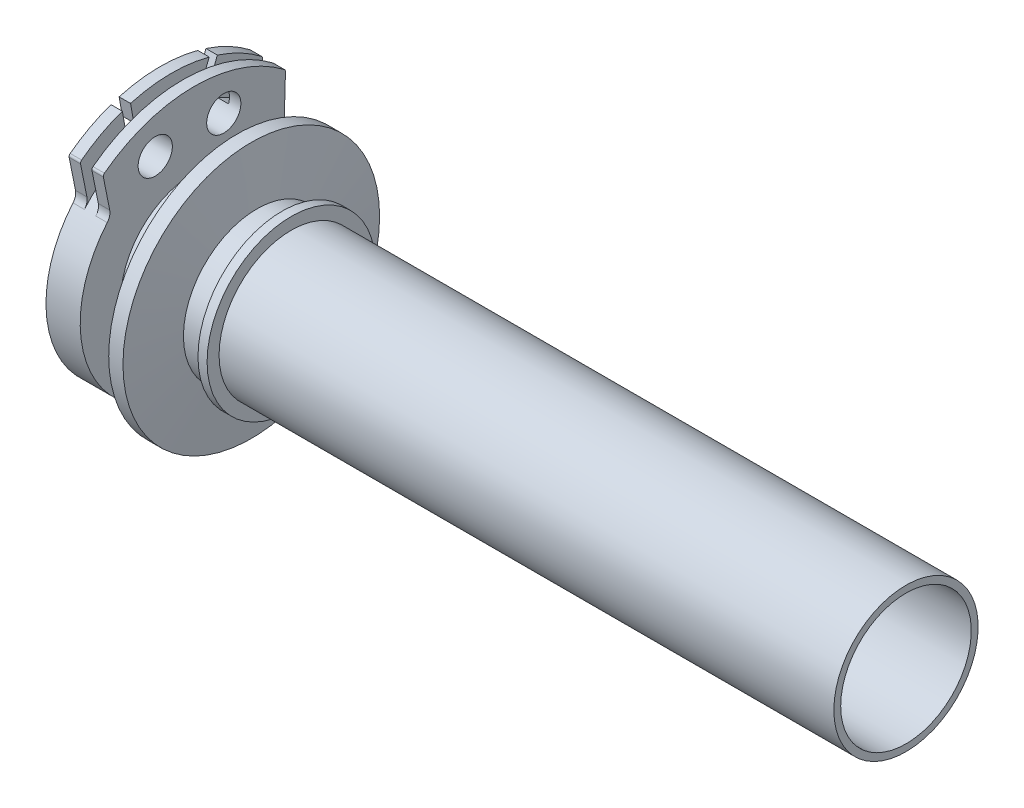
from build123d import *
from build123d.topology import SkipClean

# Parameters (mm, degrees)
SKETCH5_W          = 2
SKETCH5_H          = 25
SKETCH2_R          = 3
CUT_EXTRUDE1_DEPTH = 6
FILLET1_R          = 2
CUT_EXTRUDE2_DEPTH = 6
FILLET2_R          = 0.5
CUT_EXTRUDE3_REACH = 132.8


with BuildPart() as part:
    # Sketch1 → Revolve1 (revolve)
    with BuildSketch(Plane.XY, mode=Mode.PRIVATE) as revolve1_sk:
        Polygon((130.8, 11.45), (0, 11.45), (0, 26), (6, 26), (6, 12.9), (10, 12.9), (10, 15.5), (12, 15.5), (12, 14), (13, 14), (13.5, 22.5), (16, 22.5), (17, 12.9), (21.4, 12.9), (21.4, 14.75), (23, 14.75), (23, 12.65), (130.8, 12.65), align=None)
    revolve(revolve1_sk.sketch.rotate(Axis((0, 0, 0), (1, 0, 0)), 90), axis=Axis((0, 0, 0), (1, 0, 0)))  # turned: the seam where the file's is

    # Sketch5 → Cut-Revolve1 (revolve, cut)
    with BuildSketch(Plane.XY, mode=Mode.PRIVATE) as cut_revolve1_sk:
        with Locations((3, 32.5)):
            Rectangle(SKETCH5_W, SKETCH5_H)
    revolve(cut_revolve1_sk.sketch.rotate(Axis((0, 0, 0), (-1, 0, 0)), 270), axis=Axis((0, 0, 0), (-1, 0, 0)), mode=Mode.SUBTRACT)  # turned: the seam where the file's is

    # Sketch2 → Cut-Extrude1 (cut)
    with SkipClean():  # keep this step's faces unmerged: merging them makes the solid invalid here
        with BuildSketch(Plane.ZY):
            with Locations((-5.176381, 19.318517)):
                Circle(SKETCH2_R)
            with Locations((6.840403, 18.793852)):
                Circle(SKETCH2_R)
            with BuildLine():
                Line((14.627074, 13.639967), (16, 20.493902))
                ThreePointArc((16, 20.493902), (0, -26), (-16, 20.493902))
                Line((-16, 20.493902), (-15.760215, 12.31323))
                ThreePointArc((-15.760215, 12.31323), (0.872388, -19.980964), (14.627074, 13.639967))
            make_face()
        extrude(amount=-CUT_EXTRUDE1_DEPTH, mode=Mode.SUBTRACT)

    # Fillet1
    fillet1_edges = [part.edges().sort_by_distance(p)[0] for p in [
        (1, 12.31323, -15.760215),
        (5, 12.31323, -15.760215),
        (1, 13.639967, 14.627074),
        (5, 13.639967, 14.627074),
    ]]
    fillet(fillet1_edges, radius=FILLET1_R)

    # Sketch3 → Cut-Extrude2 (cut)
    with SkipClean():  # keep this step's faces unmerged: merging them makes the solid invalid here
        with BuildSketch(Plane.ZY):
            with BuildLine():
                Line((-16.968292, -1.037825), (-19.995549, -0.421923))
                ThreePointArc((-19.995549, -0.421923), (-12.586408, -15.542919), (3.744606, -19.646321))
                Line((3.744606, -19.646321), (2.51276, -16.81327))
                ThreePointArc((2.51276, -16.81327), (-10.698447, -13.211481), (-16.968292, -1.037825))
            make_face()
        extrude(amount=-CUT_EXTRUDE2_DEPTH, mode=Mode.SUBTRACT)

    # Fillet2
    fillet2_edges = [part.edges().sort_by_distance(p)[0] for p in [
        (3, -19.646321, 3.744606),
        (3, -0.421923, -19.995549),
        (1, 20.493902, 16),
        (5, 20.493902, 16),
        (1, 20.493902, -16),
        (5, 20.493902, -16),
    ]]
    fillet(fillet2_edges, radius=FILLET2_R)

    # Sketch4 → Cut-Extrude3 (cut, up to next)
    with BuildSketch(Plane.ZY, mode=Mode.PRIVATE) as cut_extrude3_sk1:
        Polygon((-5.843402, 18.975614), (-4.509359, 19.661419), (-10.480395, 35.216499), (-11.814438, 34.530693), align=None)
    cut_extrude3_tool1 = extrude(cut_extrude3_sk1.sketch, amount=-CUT_EXTRUDE3_REACH, mode=Mode.PRIVATE) & part.part
    add(cut_extrude3_tool1.solids().sort_by_distance((0, 27.096056, -8.161899))[0], mode=Mode.SUBTRACT)
    # Sketch4 → Cut-Extrude3 (cut, up to next)
    with BuildSketch(Plane.ZY, mode=Mode.PRIVATE) as cut_extrude3_sk2:
        Polygon((6.108448, 18.957382), (7.572358, 18.630323), (10.539953, 35.460393), (9.076043, 35.787451), align=None)
    cut_extrude3_tool2 = extrude(cut_extrude3_sk2.sketch, amount=-CUT_EXTRUDE3_REACH, mode=Mode.PRIVATE) & part.part
    add(cut_extrude3_tool2.solids().sort_by_distance((0, 27.208887, 8.324201))[0], mode=Mode.SUBTRACT)


solid = part.part
